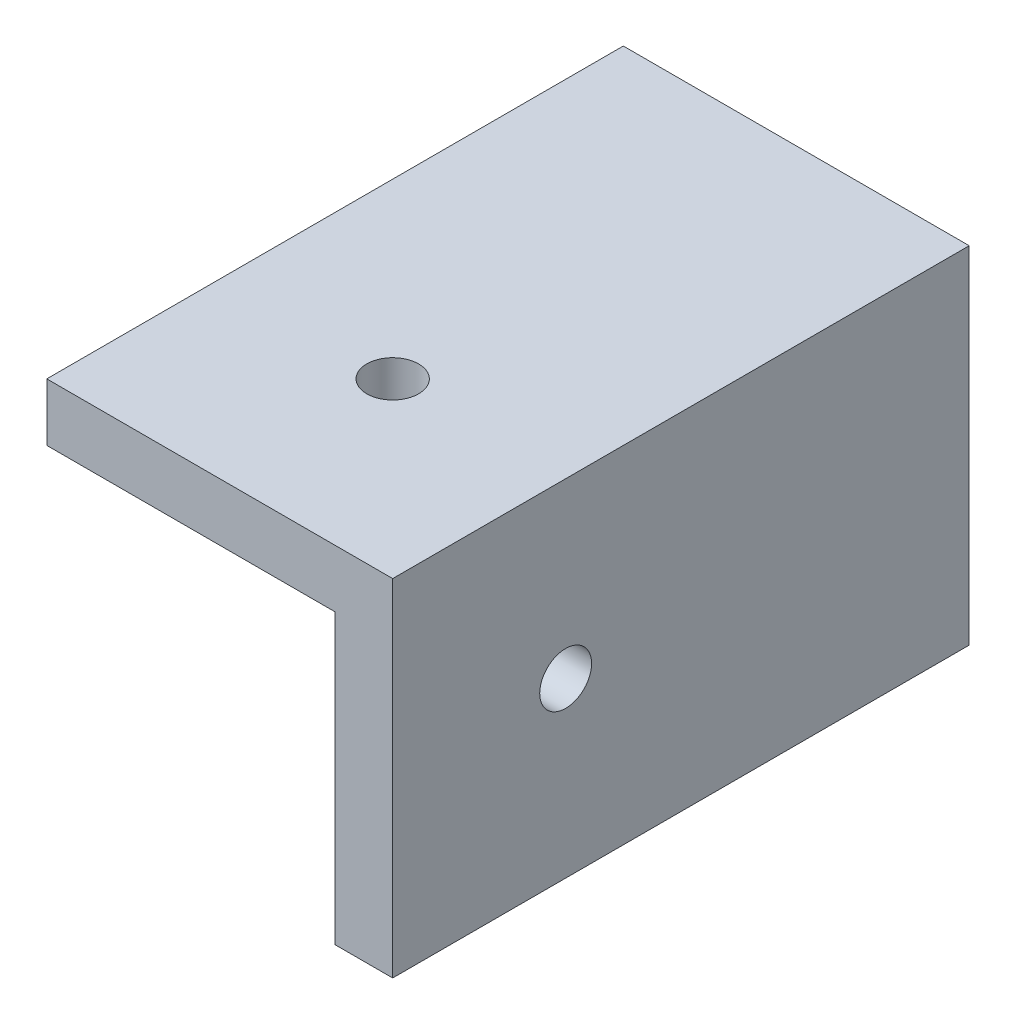
from build123d import *

# Parameters (mm, degrees)
ESBO_O1_W                         = 30
ESBO_O1_H                         = 30
RESSALTO_EXTRUS_O1_DEPTH          = 50
CORTE_EXTRUS_O1_START             = -5
ESBO_O2_W                         = 25
ESBO_O2_H                         = 5
CORTE_EXTRUS_O1_DEPTH             = 26
CORTE_EXTRUS_O2_START             = -5
ESBO_O3_W                         = 25
ESBO_O3_H                         = 25
CORTE_EXTRUS_O2_DEPTH             = 26
FURO_COM_FOLGA_DE_M41_D           = 4.5
FURO_COM_FOLGA_DE_M41_ON_FACE_2_D = 4.5


with BuildPart() as part:
    # Esboço1 → Ressalto-extrusão1 (new body)
    with BuildSketch(Plane.XY):
        with Locations((-15, 15)):
            Rectangle(ESBO_O1_W, ESBO_O1_H)
    extrude(amount=RESSALTO_EXTRUS_O1_DEPTH)

    # Esboço2 → Corte-extrusão1 (cut, through all)
    with BuildSketch(Plane(origin=(0, 30, 0), x_dir=(1, 0, 0), z_dir=(0, 1, 0)).offset(CORTE_EXTRUS_O1_START)):
        with Locations((-17.5, -12.5)):
            Rectangle(ESBO_O2_W, ESBO_O2_H)
    extrude(amount=-CORTE_EXTRUS_O1_DEPTH, mode=Mode.SUBTRACT)

    # Esboço3 → Corte-extrusão2 (cut, through all)
    with BuildSketch(Plane(origin=(0, 30, 0), x_dir=(1, 0, 0), z_dir=(0, 1, 0)).offset(CORTE_EXTRUS_O2_START)):
        with Locations((-17.5, -37.5)):
            Rectangle(ESBO_O3_W, ESBO_O3_H)
    extrude(amount=-CORTE_EXTRUS_O2_DEPTH, mode=Mode.SUBTRACT)

    # Furo com folga de M41 (through all)
    with Locations(Plane(origin=(-5, 15, 35), x_dir=(0, 0, -1), z_dir=(-1, 0, 0))):
        with Locations((0, 0)):
            Hole(FURO_COM_FOLGA_DE_M41_D / 2)

    # Furo com folga de M41 on face 2 (through all)
    with Locations(Plane(origin=(-15, 25, 35), x_dir=(0, 0, -1), z_dir=(0, -1, 0))):
        with Locations((0, 0)):
            Hole(FURO_COM_FOLGA_DE_M41_ON_FACE_2_D / 2)


solid = part.part
